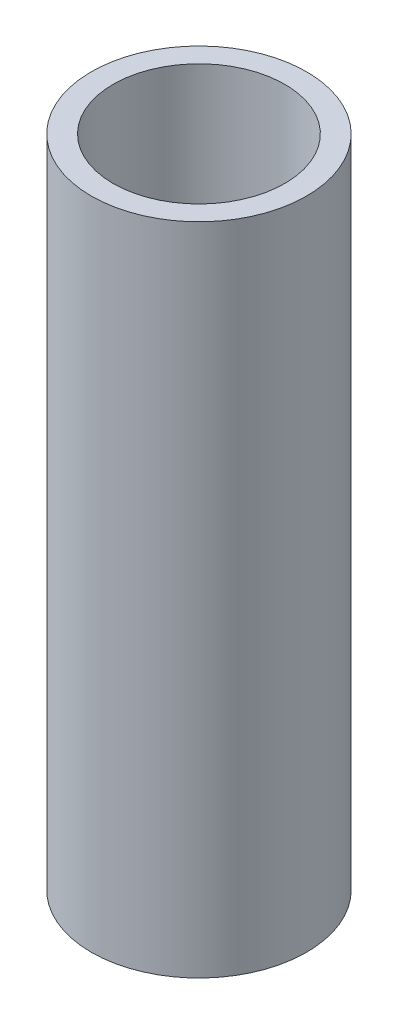
from build123d import *

# Parameters (mm, degrees)
SKETCH1_R           = 16.7005
SKETCH1_R_2         = 13.3223
BOSS_EXTRUDE1_DEPTH = 101.6


with BuildPart() as part:
    # Sketch1 → Boss-Extrude1 (new body)
    with BuildSketch(Plane(origin=(0, 0, 0), x_dir=(1, 0, 0), z_dir=(0, 1, 0))):
        Circle(SKETCH1_R)
        Circle(SKETCH1_R_2, mode=Mode.SUBTRACT)
    extrude(amount=BOSS_EXTRUDE1_DEPTH)


solid = part.part
